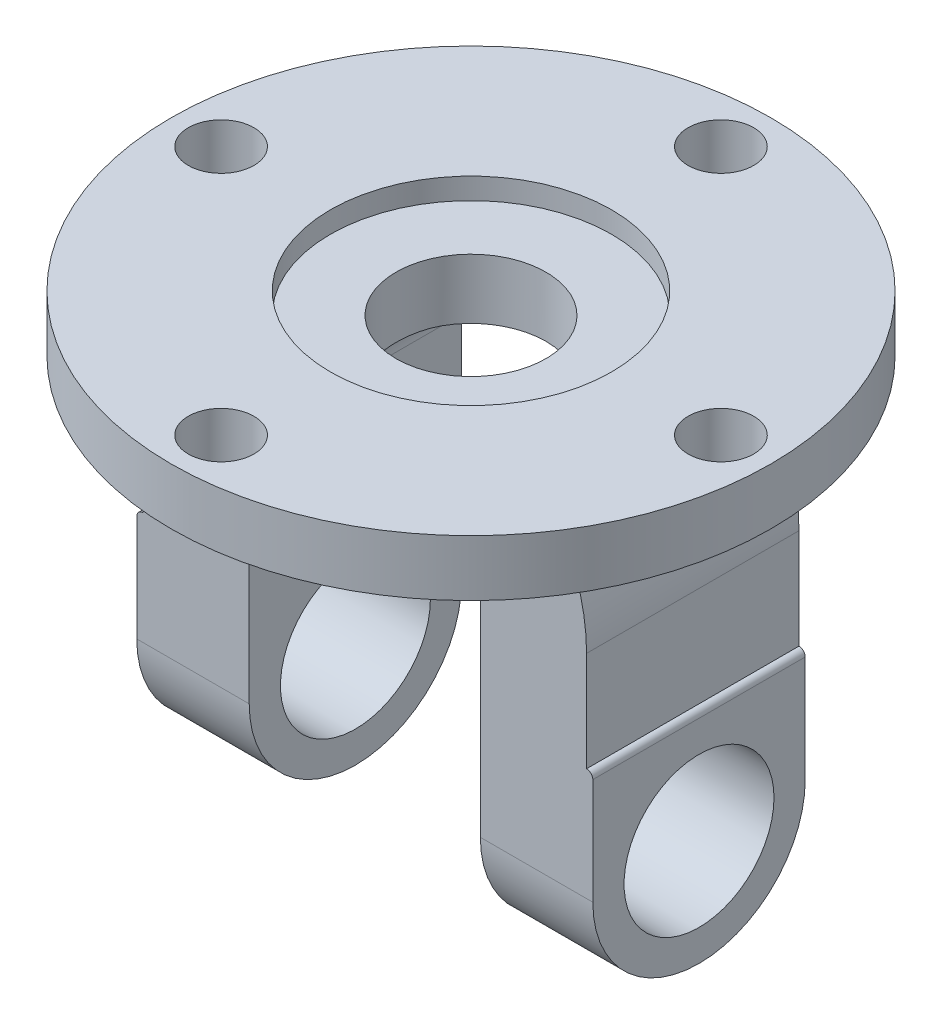
from build123d import *

# Parameters (mm, degrees)
SKETCH1_R                = 48
SKETCH1_R_2              = 5.25
BOSS_EXTRUDE1_DEPTH      = 9
SKETCH2_R                = 22.5
CUT_EXTRUDE1_DEPTH       = 3.4
SKETCH3_R                = 12
CUT_EXTRUDE2_DEPTH       = 69.11284754
BOSS_EXTRUDE2_DEPTH      = 17
BOSS_EXTRUDE2_DEPTH_BACK = 17
CUT_EXTRUDE3_DEPTH       = 4.5
CUT_EXTRUDE3_DEPTH_BACK  = 4.5
SKETCH5_R                = 12
CUT_EXTRUDE4_DEPTH       = 119.039188408
CUT_EXTRUDE4_DEPTH_BACK  = 119.039188408
CUT_EXTRUDE5_DEPTH       = 118.474465311
CUT_EXTRUDE5_DEPTH_BACK  = 118.474465311
SKETCH8_R                = 12


with BuildPart() as part:
    # Sketch1 → Boss-Extrude1 (new body)
    with BuildSketch(Plane(origin=(0, 0, 0), x_dir=(1, 0, 0), z_dir=(0, 1, 0))):
        Circle(SKETCH1_R)
        with Locations((0, 40)):
            Circle(SKETCH1_R_2, mode=Mode.SUBTRACT)
        with Locations((40, 0)):
            Circle(SKETCH1_R_2, mode=Mode.SUBTRACT)
        with Locations((0, -40)):
            Circle(SKETCH1_R_2, mode=Mode.SUBTRACT)
        with Locations((-40, 0)):
            Circle(SKETCH1_R_2, mode=Mode.SUBTRACT)
    extrude(amount=BOSS_EXTRUDE1_DEPTH)

    # Sketch2 → Cut-Extrude1 (cut)
    with BuildSketch(Plane(origin=(0, 9, 0), x_dir=(1, 0, 0), z_dir=(0, 1, 0))):
        Circle(SKETCH2_R)
    extrude(amount=-CUT_EXTRUDE1_DEPTH, mode=Mode.SUBTRACT)

    # Sketch3 → Cut-Extrude2 (cut, through all)
    with BuildSketch(Plane(origin=(0, 5.6, 0), x_dir=(1, 0, 0), z_dir=(0, 1, 0))):
        Circle(SKETCH3_R)
    extrude(amount=-CUT_EXTRUDE2_DEPTH, mode=Mode.SUBTRACT)

    # Sketch4 → Boss-Extrude2 (add, two sides: drawn at the far end of the back side and taken through both)
    with BuildSketch(Plane.XY.offset(-BOSS_EXTRUDE2_DEPTH_BACK)):
        with BuildLine():
            Line((-36.5, -66), (-36.5, -32))
            ThreePointArc((-36.5, -32), (-36.207106781, -31.292893219), (-35.5, -31))
            Line((-35.5, -31), (-35.5, -15))
            ThreePointArc((-35.5, -15), (-34.482827555, -7.237912652), (-31.5, 0))
            Line((-31.5, 0), (31.5, 0))
            ThreePointArc((31.5, 0), (34.482827555, -7.237912652), (35.5, -15))
            Line((35.5, -15), (35.5, -31))
            ThreePointArc((35.5, -31), (36.207106781, -31.292893219), (36.5, -32))
            Line((36.5, -32), (36.5, -66))
            ThreePointArc((36.5, -66), (36.207106781, -66.707106781), (35.5, -67))
            Line((35.5, -67), (19.5, -67))
            ThreePointArc((19.5, -67), (18.792893219, -66.707106781), (18.5, -66))
            Line((18.5, -66), (18.5, -12))
            ThreePointArc((18.5, -12), (16.156854249, -6.343145751), (10.5, -4))
            Line((10.5, -4), (-10.5, -4))
            ThreePointArc((-10.5, -4), (-16.156854249, -6.343145751), (-18.5, -12))
            Line((-18.5, -12), (-18.5, -66))
            ThreePointArc((-18.5, -66), (-18.792893219, -66.707106781), (-19.5, -67))
            Line((-19.5, -67), (-35.5, -67))
            ThreePointArc((-35.5, -67), (-36.207106781, -66.707106781), (-36.5, -66))
        make_face()
    extrude(amount=BOSS_EXTRUDE2_DEPTH + BOSS_EXTRUDE2_DEPTH_BACK)

    # Sketch5 → Cut-Extrude3 (cut, two sides: drawn at the far end of the back side and taken through both)
    with BuildSketch(Plane.XZ.offset(4).offset(-CUT_EXTRUDE3_DEPTH_BACK)):
        Circle(SKETCH5_R)
    extrude(amount=CUT_EXTRUDE3_DEPTH + CUT_EXTRUDE3_DEPTH_BACK, mode=Mode.SUBTRACT)

    # Sketch7 → Cut-Extrude4 (cut, two sides: drawn at the far end of the back side and taken through both)
    with BuildSketch(Plane.ZY.offset(36.5).offset(-CUT_EXTRUDE4_DEPTH_BACK)):
        with BuildLine():
            Line((-17, 0), (-17, -49))
            ThreePointArc((-17, -49), (0, -66), (17, -49))
            Line((17, -49), (17, 0))
            Line((17, 0), (31.554606814, 0))
            Line((31.554606814, 0), (31.554606814, -74.298240475))
            Line((31.554606814, -74.298240475), (-29.742859054, -74.298240475))
            Line((-29.742859054, -74.298240475), (-29.742859054, 0))
            Line((-29.742859054, 0), (-17, 0))
        make_face()
    extrude(amount=CUT_EXTRUDE4_DEPTH + CUT_EXTRUDE4_DEPTH_BACK, mode=Mode.SUBTRACT)

    # Sketch8 → Cut-Extrude5 (cut, two sides: drawn at the far end of the back side and taken through both)
    with BuildSketch(Plane(origin=(36.5, 0, 0), x_dir=(0, 0, -1), z_dir=(1, 0, 0)).offset(-CUT_EXTRUDE5_DEPTH_BACK)):
        with Locations((0, -49)):
            Circle(SKETCH8_R)
    extrude(amount=CUT_EXTRUDE5_DEPTH + CUT_EXTRUDE5_DEPTH_BACK, mode=Mode.SUBTRACT)


solid = part.part
